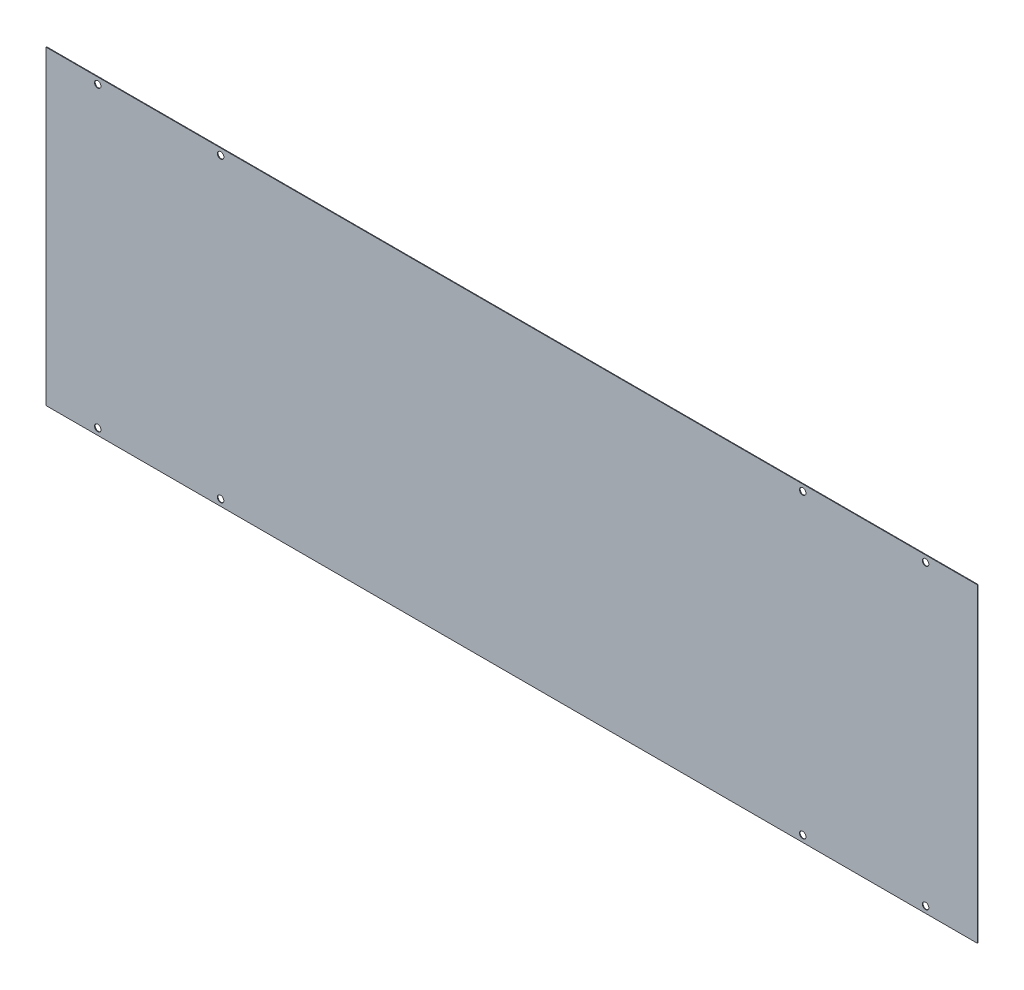
from build123d import *

# Parameters (mm, degrees)
SKETCH1_W                   = 914.4
SKETCH1_H                   = 304.8
BOSS_EXTRUDE1_DEPTH         = 0.635
F_1_4_0_25_DIAMETER_HOLE1_D = 6.35


with BuildPart() as part:
    # Sketch1 → Boss-Extrude1 (new body)
    with BuildSketch(Plane.XY):
        Rectangle(SKETCH1_W, SKETCH1_H)
    extrude(amount=BOSS_EXTRUDE1_DEPTH)

    # 1/4 (0.25) Diameter Hole1 (through all)
    with Locations(Plane.XY.offset(0.635)):
        with Locations((285.75, 146.05), (406.4, 146.05), (406.4, -146.05), (285.75, -146.05)):
            f_1_4_0_25_diameter_hole1 = Hole(F_1_4_0_25_DIAMETER_HOLE1_D / 2)

    # Mirror1: 1/4 (0.25) Diameter Hole1 across plane
    add(f_1_4_0_25_diameter_hole1.mirror(Plane(origin=(0, 0, 0), x_dir=(0, 0, 1), z_dir=(1, 0, 0))), mode=Mode.SUBTRACT)


solid = part.part
